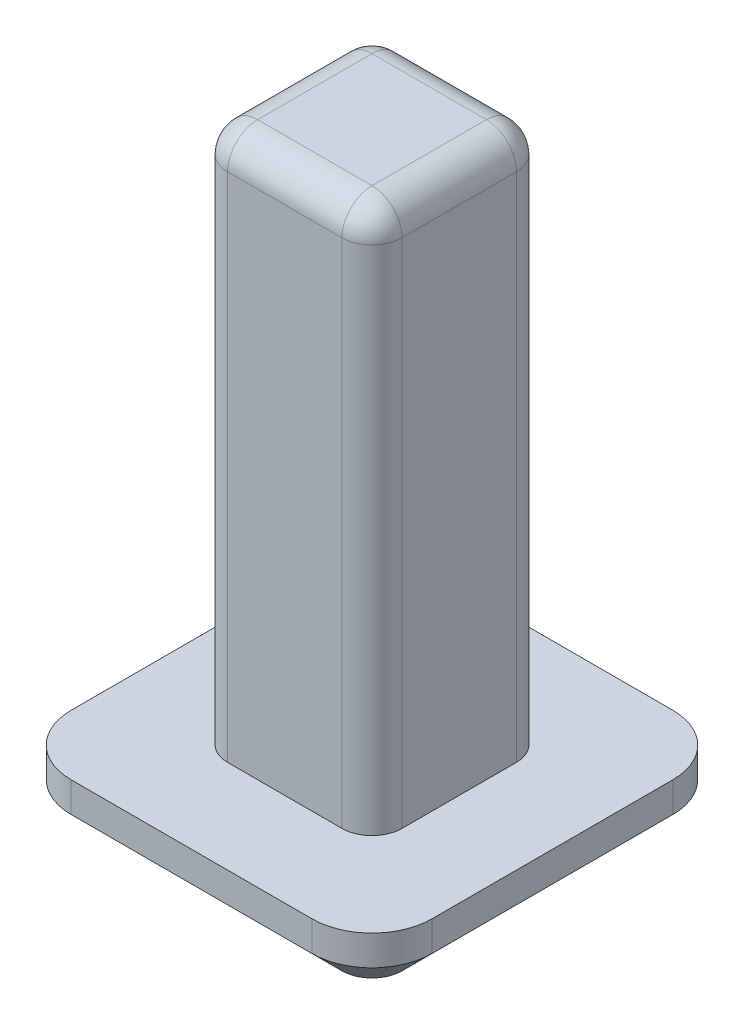
from build123d import *

# Parameters (mm, degrees)
SKETCH1_W           = 6
SKETCH1_H           = 6
BOSS_EXTRUDE1_DEPTH = 1
FILLET1_R           = 1
SKETCH2_W           = 2.9
SKETCH2_H           = 2.9
BOSS_EXTRUDE2_DEPTH = 9
FILLET2_R           = 0.5
FILLET3_R           = 0.5
CHAMFER1_SIZE       = 0.5


with BuildPart() as part:
    # Sketch1 → Boss-Extrude1 (new body)
    with BuildSketch(Plane(origin=(0, 0, 0), x_dir=(1, 0, 0), z_dir=(0, 1, 0))):
        Rectangle(SKETCH1_W, SKETCH1_H)
    extrude(amount=BOSS_EXTRUDE1_DEPTH)

    # Fillet1
    fillet1_edges = [part.edges().sort_by_distance(p)[0] for p in [
        (3, 0.5, 3),
        (-3, 0.5, 3),
        (-3, 0.5, -3),
        (3, 0.5, -3),
    ]]
    fillet(fillet1_edges, radius=FILLET1_R)

    # Sketch2 → Boss-Extrude2 (add)
    with BuildSketch(Plane(origin=(0, 1, 0), x_dir=(1, 0, 0), z_dir=(0, 1, 0))):
        Rectangle(SKETCH2_W, SKETCH2_H)
    extrude(amount=BOSS_EXTRUDE2_DEPTH)

    # Fillet2
    fillet2_edges = [part.edges().sort_by_distance(p)[0] for p in [
        (1.45, 5.5, 1.45),
        (1.45, 5.5, -1.45),
        (-1.45, 5.5, -1.45),
        (-1.45, 5.5, 1.45),
    ]]
    fillet(fillet2_edges, radius=FILLET2_R)

    # Fillet3
    fillet3_edges = [part.edges().sort_by_distance(p)[0] for p in [
        (0, 10, -1.45),
        (1.45, 10, 0),
        (-1.45, 10, 0),
        (0, 10, 1.45),
        (-1.303553391, 10, 1.303553391),
        (1.303553391, 10, 1.303553391),
        (-1.303553391, 10, -1.303553391),
        (1.303553391, 10, -1.303553391),
    ]]
    fillet(fillet3_edges, radius=FILLET3_R)

    # Chamfer1
    chamfer1_edges = [part.edges().sort_by_distance(p)[0] for p in [
        (0, 0, 3),
        (3, 0, 0),
        (-3, 0, 0),
        (0, 0, -3),
        (2.707106781, 0, 2.707106781),
        (2.707106781, 0, -2.707106781),
        (-2.707106781, 0, -2.707106781),
        (-2.707106781, 0, 2.707106781),
    ]]
    chamfer(chamfer1_edges, length=CHAMFER1_SIZE)


solid = part.part
